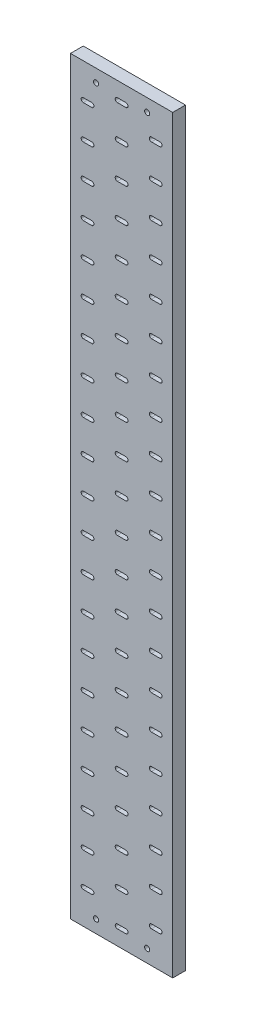
from build123d import *

# Parameters (mm, degrees)
SKETCH_1_W      = 120
SKETCH_1_H      = 880
SKETCH_1_R      = 3
EXTRUDE_1_DEPTH = 15


with BuildPart() as part:
    # 草图1 → 凸台-拉伸1 (new body)
    with BuildSketch(Plane.XY):
        with Locations((499.301234579, 90.244075086)):
            Rectangle(SKETCH_1_W, SKETCH_1_H)
        with Locations((529.301234579, 515.244075086)):
            Circle(SKETCH_1_R, mode=Mode.SUBTRACT)
        with Locations((529.301234579, -334.755924914)):
            Circle(SKETCH_1_R, mode=Mode.SUBTRACT)
        with Locations((469.301234579, 515.244075086)):
            Circle(SKETCH_1_R, mode=Mode.SUBTRACT)
        with Locations((469.301234579, -334.755924914)):
            Circle(SKETCH_1_R, mode=Mode.SUBTRACT)
        with BuildLine():
            Line((544.301234579, 492.744075086), (534.301234579, 492.744075086))
            ThreePointArc((534.301234579, 492.744075086), (531.801234579, 490.244075086), (534.301234579, 487.744075086))
            Line((534.301234579, 487.744075086), (544.301234579, 487.744075086))
            ThreePointArc((544.301234579, 487.744075086), (546.801234579, 490.244075086), (544.301234579, 492.744075086))
        make_face(mode=Mode.SUBTRACT)
        with BuildLine():
            Line((464.301234579, 492.744075086), (454.301234579, 492.744075086))
            ThreePointArc((454.301234579, 492.744075086), (451.801234579, 490.244075086), (454.301234579, 487.744075086))
            Line((454.301234579, 487.744075086), (464.301234579, 487.744075086))
            ThreePointArc((464.301234579, 487.744075086), (466.801234579, 490.244075086), (464.301234579, 492.744075086))
        make_face(mode=Mode.SUBTRACT)
        with BuildLine():
            Line((504.301234579, 472.744075086), (494.301234579, 472.744075086))
            ThreePointArc((494.301234579, 472.744075086), (491.801234579, 470.244075086), (494.301234579, 467.744075086))
            Line((494.301234579, 467.744075086), (504.301234579, 467.744075086))
            ThreePointArc((504.301234579, 467.744075086), (506.801234579, 470.244075086), (504.301234579, 472.744075086))
        make_face(mode=Mode.SUBTRACT)
        with BuildLine():
            Line((504.301234579, 512.744075086), (494.301234579, 512.744075086))
            ThreePointArc((494.301234579, 512.744075086), (491.801234579, 510.244075086), (494.301234579, 507.744075086))
            Line((494.301234579, 507.744075086), (504.301234579, 507.744075086))
            ThreePointArc((504.301234579, 507.744075086), (506.801234579, 510.244075086), (504.301234579, 512.744075086))
        make_face(mode=Mode.SUBTRACT)
        with BuildLine():
            Line((544.301234579, 452.744075086), (534.301234579, 452.744075086))
            ThreePointArc((534.301234579, 452.744075086), (531.801234579, 450.244075086), (534.301234579, 447.744075086))
            Line((534.301234579, 447.744075086), (544.301234579, 447.744075086))
            ThreePointArc((544.301234579, 447.744075086), (546.801234579, 450.244075086), (544.301234579, 452.744075086))
        make_face(mode=Mode.SUBTRACT)
        with BuildLine():
            Line((464.301234579, 452.744075086), (454.301234579, 452.744075086))
            ThreePointArc((454.301234579, 452.744075086), (451.801234579, 450.244075086), (454.301234579, 447.744075086))
            Line((454.301234579, 447.744075086), (464.301234579, 447.744075086))
            ThreePointArc((464.301234579, 447.744075086), (466.801234579, 450.244075086), (464.301234579, 452.744075086))
        make_face(mode=Mode.SUBTRACT)
        with BuildLine():
            Line((504.301234579, 432.744075086), (494.301234579, 432.744075086))
            ThreePointArc((494.301234579, 432.744075086), (491.801234579, 430.244075086), (494.301234579, 427.744075086))
            Line((494.301234579, 427.744075086), (504.301234579, 427.744075086))
            ThreePointArc((504.301234579, 427.744075086), (506.801234579, 430.244075086), (504.301234579, 432.744075086))
        make_face(mode=Mode.SUBTRACT)
        with BuildLine():
            Line((544.301234579, 412.744075086), (534.301234579, 412.744075086))
            ThreePointArc((534.301234579, 412.744075086), (531.801234579, 410.244075086), (534.301234579, 407.744075086))
            Line((534.301234579, 407.744075086), (544.301234579, 407.744075086))
            ThreePointArc((544.301234579, 407.744075086), (546.801234579, 410.244075086), (544.301234579, 412.744075086))
        make_face(mode=Mode.SUBTRACT)
        with BuildLine():
            Line((464.301234579, 412.744075086), (454.301234579, 412.744075086))
            ThreePointArc((454.301234579, 412.744075086), (451.801234579, 410.244075086), (454.301234579, 407.744075086))
            Line((454.301234579, 407.744075086), (464.301234579, 407.744075086))
            ThreePointArc((464.301234579, 407.744075086), (466.801234579, 410.244075086), (464.301234579, 412.744075086))
        make_face(mode=Mode.SUBTRACT)
        with BuildLine():
            Line((504.301234579, 392.744075086), (494.301234579, 392.744075086))
            ThreePointArc((494.301234579, 392.744075086), (491.801234579, 390.244075086), (494.301234579, 387.744075086))
            Line((494.301234579, 387.744075086), (504.301234579, 387.744075086))
            ThreePointArc((504.301234579, 387.744075086), (506.801234579, 390.244075086), (504.301234579, 392.744075086))
        make_face(mode=Mode.SUBTRACT)
        with BuildLine():
            Line((544.301234579, 372.744075086), (534.301234579, 372.744075086))
            ThreePointArc((534.301234579, 372.744075086), (531.801234579, 370.244075086), (534.301234579, 367.744075086))
            Line((534.301234579, 367.744075086), (544.301234579, 367.744075086))
            ThreePointArc((544.301234579, 367.744075086), (546.801234579, 370.244075086), (544.301234579, 372.744075086))
        make_face(mode=Mode.SUBTRACT)
        with BuildLine():
            Line((464.301234579, 372.744075086), (454.301234579, 372.744075086))
            ThreePointArc((454.301234579, 372.744075086), (451.801234579, 370.244075086), (454.301234579, 367.744075086))
            Line((454.301234579, 367.744075086), (464.301234579, 367.744075086))
            ThreePointArc((464.301234579, 367.744075086), (466.801234579, 370.244075086), (464.301234579, 372.744075086))
        make_face(mode=Mode.SUBTRACT)
        with BuildLine():
            Line((504.301234579, 352.744075086), (494.301234579, 352.744075086))
            ThreePointArc((494.301234579, 352.744075086), (491.801234579, 350.244075086), (494.301234579, 347.744075086))
            Line((494.301234579, 347.744075086), (504.301234579, 347.744075086))
            ThreePointArc((504.301234579, 347.744075086), (506.801234579, 350.244075086), (504.301234579, 352.744075086))
        make_face(mode=Mode.SUBTRACT)
        with BuildLine():
            Line((544.301234579, 332.744075086), (534.301234579, 332.744075086))
            ThreePointArc((534.301234579, 332.744075086), (531.801234579, 330.244075086), (534.301234579, 327.744075086))
            Line((534.301234579, 327.744075086), (544.301234579, 327.744075086))
            ThreePointArc((544.301234579, 327.744075086), (546.801234579, 330.244075086), (544.301234579, 332.744075086))
        make_face(mode=Mode.SUBTRACT)
        with BuildLine():
            Line((464.301234579, 332.744075086), (454.301234579, 332.744075086))
            ThreePointArc((454.301234579, 332.744075086), (451.801234579, 330.244075086), (454.301234579, 327.744075086))
            Line((454.301234579, 327.744075086), (464.301234579, 327.744075086))
            ThreePointArc((464.301234579, 327.744075086), (466.801234579, 330.244075086), (464.301234579, 332.744075086))
        make_face(mode=Mode.SUBTRACT)
        with BuildLine():
            Line((504.301234579, 312.744075086), (494.301234579, 312.744075086))
            ThreePointArc((494.301234579, 312.744075086), (491.801234579, 310.244075086), (494.301234579, 307.744075086))
            Line((494.301234579, 307.744075086), (504.301234579, 307.744075086))
            ThreePointArc((504.301234579, 307.744075086), (506.801234579, 310.244075086), (504.301234579, 312.744075086))
        make_face(mode=Mode.SUBTRACT)
        with BuildLine():
            Line((544.301234579, 292.744075086), (534.301234579, 292.744075086))
            ThreePointArc((534.301234579, 292.744075086), (531.801234579, 290.244075086), (534.301234579, 287.744075086))
            Line((534.301234579, 287.744075086), (544.301234579, 287.744075086))
            ThreePointArc((544.301234579, 287.744075086), (546.801234579, 290.244075086), (544.301234579, 292.744075086))
        make_face(mode=Mode.SUBTRACT)
        with BuildLine():
            Line((464.301234579, 292.744075086), (454.301234579, 292.744075086))
            ThreePointArc((454.301234579, 292.744075086), (451.801234579, 290.244075086), (454.301234579, 287.744075086))
            Line((454.301234579, 287.744075086), (464.301234579, 287.744075086))
            ThreePointArc((464.301234579, 287.744075086), (466.801234579, 290.244075086), (464.301234579, 292.744075086))
        make_face(mode=Mode.SUBTRACT)
        with BuildLine():
            Line((504.301234579, 272.744075086), (494.301234579, 272.744075086))
            ThreePointArc((494.301234579, 272.744075086), (491.801234579, 270.244075086), (494.301234579, 267.744075086))
            Line((494.301234579, 267.744075086), (504.301234579, 267.744075086))
            ThreePointArc((504.301234579, 267.744075086), (506.801234579, 270.244075086), (504.301234579, 272.744075086))
        make_face(mode=Mode.SUBTRACT)
        with BuildLine():
            Line((544.301234579, 252.744075086), (534.301234579, 252.744075086))
            ThreePointArc((534.301234579, 252.744075086), (531.801234579, 250.244075086), (534.301234579, 247.744075086))
            Line((534.301234579, 247.744075086), (544.301234579, 247.744075086))
            ThreePointArc((544.301234579, 247.744075086), (546.801234579, 250.244075086), (544.301234579, 252.744075086))
        make_face(mode=Mode.SUBTRACT)
        with BuildLine():
            Line((464.301234579, 252.744075086), (454.301234579, 252.744075086))
            ThreePointArc((454.301234579, 252.744075086), (451.801234579, 250.244075086), (454.301234579, 247.744075086))
            Line((454.301234579, 247.744075086), (464.301234579, 247.744075086))
            ThreePointArc((464.301234579, 247.744075086), (466.801234579, 250.244075086), (464.301234579, 252.744075086))
        make_face(mode=Mode.SUBTRACT)
        with BuildLine():
            Line((504.301234579, 232.744075086), (494.301234579, 232.744075086))
            ThreePointArc((494.301234579, 232.744075086), (491.801234579, 230.244075086), (494.301234579, 227.744075086))
            Line((494.301234579, 227.744075086), (504.301234579, 227.744075086))
            ThreePointArc((504.301234579, 227.744075086), (506.801234579, 230.244075086), (504.301234579, 232.744075086))
        make_face(mode=Mode.SUBTRACT)
        with BuildLine():
            Line((544.301234579, 212.744075086), (534.301234579, 212.744075086))
            ThreePointArc((534.301234579, 212.744075086), (531.801234579, 210.244075086), (534.301234579, 207.744075086))
            Line((534.301234579, 207.744075086), (544.301234579, 207.744075086))
            ThreePointArc((544.301234579, 207.744075086), (546.801234579, 210.244075086), (544.301234579, 212.744075086))
        make_face(mode=Mode.SUBTRACT)
        with BuildLine():
            Line((464.301234579, 212.744075086), (454.301234579, 212.744075086))
            ThreePointArc((454.301234579, 212.744075086), (451.801234579, 210.244075086), (454.301234579, 207.744075086))
            Line((454.301234579, 207.744075086), (464.301234579, 207.744075086))
            ThreePointArc((464.301234579, 207.744075086), (466.801234579, 210.244075086), (464.301234579, 212.744075086))
        make_face(mode=Mode.SUBTRACT)
        with BuildLine():
            Line((504.301234579, 192.744075086), (494.301234579, 192.744075086))
            ThreePointArc((494.301234579, 192.744075086), (491.801234579, 190.244075086), (494.301234579, 187.744075086))
            Line((494.301234579, 187.744075086), (504.301234579, 187.744075086))
            ThreePointArc((504.301234579, 187.744075086), (506.801234579, 190.244075086), (504.301234579, 192.744075086))
        make_face(mode=Mode.SUBTRACT)
        with BuildLine():
            Line((544.301234579, 172.744075086), (534.301234579, 172.744075086))
            ThreePointArc((534.301234579, 172.744075086), (531.801234579, 170.244075086), (534.301234579, 167.744075086))
            Line((534.301234579, 167.744075086), (544.301234579, 167.744075086))
            ThreePointArc((544.301234579, 167.744075086), (546.801234579, 170.244075086), (544.301234579, 172.744075086))
        make_face(mode=Mode.SUBTRACT)
        with BuildLine():
            Line((464.301234579, 172.744075086), (454.301234579, 172.744075086))
            ThreePointArc((454.301234579, 172.744075086), (451.801234579, 170.244075086), (454.301234579, 167.744075086))
            Line((454.301234579, 167.744075086), (464.301234579, 167.744075086))
            ThreePointArc((464.301234579, 167.744075086), (466.801234579, 170.244075086), (464.301234579, 172.744075086))
        make_face(mode=Mode.SUBTRACT)
        with BuildLine():
            Line((504.301234579, 152.744075086), (494.301234579, 152.744075086))
            ThreePointArc((494.301234579, 152.744075086), (491.801234579, 150.244075086), (494.301234579, 147.744075086))
            Line((494.301234579, 147.744075086), (504.301234579, 147.744075086))
            ThreePointArc((504.301234579, 147.744075086), (506.801234579, 150.244075086), (504.301234579, 152.744075086))
        make_face(mode=Mode.SUBTRACT)
        with BuildLine():
            Line((544.301234579, 132.744075086), (534.301234579, 132.744075086))
            ThreePointArc((534.301234579, 132.744075086), (531.801234579, 130.244075086), (534.301234579, 127.744075086))
            Line((534.301234579, 127.744075086), (544.301234579, 127.744075086))
            ThreePointArc((544.301234579, 127.744075086), (546.801234579, 130.244075086), (544.301234579, 132.744075086))
        make_face(mode=Mode.SUBTRACT)
        with BuildLine():
            Line((464.301234579, 132.744075086), (454.301234579, 132.744075086))
            ThreePointArc((454.301234579, 132.744075086), (451.801234579, 130.244075086), (454.301234579, 127.744075086))
            Line((454.301234579, 127.744075086), (464.301234579, 127.744075086))
            ThreePointArc((464.301234579, 127.744075086), (466.801234579, 130.244075086), (464.301234579, 132.744075086))
        make_face(mode=Mode.SUBTRACT)
        with BuildLine():
            Line((504.301234579, 112.744075086), (494.301234579, 112.744075086))
            ThreePointArc((494.301234579, 112.744075086), (491.801234579, 110.244075086), (494.301234579, 107.744075086))
            Line((494.301234579, 107.744075086), (504.301234579, 107.744075086))
            ThreePointArc((504.301234579, 107.744075086), (506.801234579, 110.244075086), (504.301234579, 112.744075086))
        make_face(mode=Mode.SUBTRACT)
        with BuildLine():
            Line((544.301234579, 92.744075086), (534.301234579, 92.744075086))
            ThreePointArc((534.301234579, 92.744075086), (531.801234579, 90.244075086), (534.301234579, 87.744075086))
            Line((534.301234579, 87.744075086), (544.301234579, 87.744075086))
            ThreePointArc((544.301234579, 87.744075086), (546.801234579, 90.244075086), (544.301234579, 92.744075086))
        make_face(mode=Mode.SUBTRACT)
        with BuildLine():
            Line((464.301234579, 92.744075086), (454.301234579, 92.744075086))
            ThreePointArc((454.301234579, 92.744075086), (451.801234579, 90.244075086), (454.301234579, 87.744075086))
            Line((454.301234579, 87.744075086), (464.301234579, 87.744075086))
            ThreePointArc((464.301234579, 87.744075086), (466.801234579, 90.244075086), (464.301234579, 92.744075086))
        make_face(mode=Mode.SUBTRACT)
        with BuildLine():
            Line((504.301234579, 72.744075086), (494.301234579, 72.744075086))
            ThreePointArc((494.301234579, 72.744075086), (491.801234579, 70.244075086), (494.301234579, 67.744075086))
            Line((494.301234579, 67.744075086), (504.301234579, 67.744075086))
            ThreePointArc((504.301234579, 67.744075086), (506.801234579, 70.244075086), (504.301234579, 72.744075086))
        make_face(mode=Mode.SUBTRACT)
        with BuildLine():
            Line((544.301234579, 52.744075086), (534.301234579, 52.744075086))
            ThreePointArc((534.301234579, 52.744075086), (531.801234579, 50.244075086), (534.301234579, 47.744075086))
            Line((534.301234579, 47.744075086), (544.301234579, 47.744075086))
            ThreePointArc((544.301234579, 47.744075086), (546.801234579, 50.244075086), (544.301234579, 52.744075086))
        make_face(mode=Mode.SUBTRACT)
        with BuildLine():
            Line((464.301234579, 52.744075086), (454.301234579, 52.744075086))
            ThreePointArc((454.301234579, 52.744075086), (451.801234579, 50.244075086), (454.301234579, 47.744075086))
            Line((454.301234579, 47.744075086), (464.301234579, 47.744075086))
            ThreePointArc((464.301234579, 47.744075086), (466.801234579, 50.244075086), (464.301234579, 52.744075086))
        make_face(mode=Mode.SUBTRACT)
        with BuildLine():
            Line((504.301234579, 32.744075086), (494.301234579, 32.744075086))
            ThreePointArc((494.301234579, 32.744075086), (491.801234579, 30.244075086), (494.301234579, 27.744075086))
            Line((494.301234579, 27.744075086), (504.301234579, 27.744075086))
            ThreePointArc((504.301234579, 27.744075086), (506.801234579, 30.244075086), (504.301234579, 32.744075086))
        make_face(mode=Mode.SUBTRACT)
        with BuildLine():
            Line((544.301234579, 12.744075086), (534.301234579, 12.744075086))
            ThreePointArc((534.301234579, 12.744075086), (531.801234579, 10.244075086), (534.301234579, 7.744075086))
            Line((534.301234579, 7.744075086), (544.301234579, 7.744075086))
            ThreePointArc((544.301234579, 7.744075086), (546.801234579, 10.244075086), (544.301234579, 12.744075086))
        make_face(mode=Mode.SUBTRACT)
        with BuildLine():
            Line((464.301234579, 12.744075086), (454.301234579, 12.744075086))
            ThreePointArc((454.301234579, 12.744075086), (451.801234579, 10.244075086), (454.301234579, 7.744075086))
            Line((454.301234579, 7.744075086), (464.301234579, 7.744075086))
            ThreePointArc((464.301234579, 7.744075086), (466.801234579, 10.244075086), (464.301234579, 12.744075086))
        make_face(mode=Mode.SUBTRACT)
        with BuildLine():
            Line((504.301234579, -7.255924914), (494.301234579, -7.255924914))
            ThreePointArc((494.301234579, -7.255924914), (491.801234579, -9.755924914), (494.301234579, -12.255924914))
            Line((494.301234579, -12.255924914), (504.301234579, -12.255924914))
            ThreePointArc((504.301234579, -12.255924914), (506.801234579, -9.755924914), (504.301234579, -7.255924914))
        make_face(mode=Mode.SUBTRACT)
        with BuildLine():
            Line((544.301234579, -27.255924914), (534.301234579, -27.255924914))
            ThreePointArc((534.301234579, -27.255924914), (531.801234579, -29.755924914), (534.301234579, -32.255924914))
            Line((534.301234579, -32.255924914), (544.301234579, -32.255924914))
            ThreePointArc((544.301234579, -32.255924914), (546.801234579, -29.755924914), (544.301234579, -27.255924914))
        make_face(mode=Mode.SUBTRACT)
        with BuildLine():
            Line((464.301234579, -27.255924914), (454.301234579, -27.255924914))
            ThreePointArc((454.301234579, -27.255924914), (451.801234579, -29.755924914), (454.301234579, -32.255924914))
            Line((454.301234579, -32.255924914), (464.301234579, -32.255924914))
            ThreePointArc((464.301234579, -32.255924914), (466.801234579, -29.755924914), (464.301234579, -27.255924914))
        make_face(mode=Mode.SUBTRACT)
        with BuildLine():
            Line((504.301234579, -47.255924914), (494.301234579, -47.255924914))
            ThreePointArc((494.301234579, -47.255924914), (491.801234579, -49.755924914), (494.301234579, -52.255924914))
            Line((494.301234579, -52.255924914), (504.301234579, -52.255924914))
            ThreePointArc((504.301234579, -52.255924914), (506.801234579, -49.755924914), (504.301234579, -47.255924914))
        make_face(mode=Mode.SUBTRACT)
        with BuildLine():
            Line((544.301234579, -67.255924914), (534.301234579, -67.255924914))
            ThreePointArc((534.301234579, -67.255924914), (531.801234579, -69.755924914), (534.301234579, -72.255924914))
            Line((534.301234579, -72.255924914), (544.301234579, -72.255924914))
            ThreePointArc((544.301234579, -72.255924914), (546.801234579, -69.755924914), (544.301234579, -67.255924914))
        make_face(mode=Mode.SUBTRACT)
        with BuildLine():
            Line((464.301234579, -67.255924914), (454.301234579, -67.255924914))
            ThreePointArc((454.301234579, -67.255924914), (451.801234579, -69.755924914), (454.301234579, -72.255924914))
            Line((454.301234579, -72.255924914), (464.301234579, -72.255924914))
            ThreePointArc((464.301234579, -72.255924914), (466.801234579, -69.755924914), (464.301234579, -67.255924914))
        make_face(mode=Mode.SUBTRACT)
        with BuildLine():
            Line((504.301234579, -87.255924914), (494.301234579, -87.255924914))
            ThreePointArc((494.301234579, -87.255924914), (491.801234579, -89.755924914), (494.301234579, -92.255924914))
            Line((494.301234579, -92.255924914), (504.301234579, -92.255924914))
            ThreePointArc((504.301234579, -92.255924914), (506.801234579, -89.755924914), (504.301234579, -87.255924914))
        make_face(mode=Mode.SUBTRACT)
        with BuildLine():
            Line((544.301234579, -107.255924914), (534.301234579, -107.255924914))
            ThreePointArc((534.301234579, -107.255924914), (531.801234579, -109.755924914), (534.301234579, -112.255924914))
            Line((534.301234579, -112.255924914), (544.301234579, -112.255924914))
            ThreePointArc((544.301234579, -112.255924914), (546.801234579, -109.755924914), (544.301234579, -107.255924914))
        make_face(mode=Mode.SUBTRACT)
        with BuildLine():
            Line((464.301234579, -107.255924914), (454.301234579, -107.255924914))
            ThreePointArc((454.301234579, -107.255924914), (451.801234579, -109.755924914), (454.301234579, -112.255924914))
            Line((454.301234579, -112.255924914), (464.301234579, -112.255924914))
            ThreePointArc((464.301234579, -112.255924914), (466.801234579, -109.755924914), (464.301234579, -107.255924914))
        make_face(mode=Mode.SUBTRACT)
        with BuildLine():
            Line((504.301234579, -127.255924914), (494.301234579, -127.255924914))
            ThreePointArc((494.301234579, -127.255924914), (491.801234579, -129.755924914), (494.301234579, -132.255924914))
            Line((494.301234579, -132.255924914), (504.301234579, -132.255924914))
            ThreePointArc((504.301234579, -132.255924914), (506.801234579, -129.755924914), (504.301234579, -127.255924914))
        make_face(mode=Mode.SUBTRACT)
        with BuildLine():
            Line((544.301234579, -147.255924914), (534.301234579, -147.255924914))
            ThreePointArc((534.301234579, -147.255924914), (531.801234579, -149.755924914), (534.301234579, -152.255924914))
            Line((534.301234579, -152.255924914), (544.301234579, -152.255924914))
            ThreePointArc((544.301234579, -152.255924914), (546.801234579, -149.755924914), (544.301234579, -147.255924914))
        make_face(mode=Mode.SUBTRACT)
        with BuildLine():
            Line((464.301234579, -147.255924914), (454.301234579, -147.255924914))
            ThreePointArc((454.301234579, -147.255924914), (451.801234579, -149.755924914), (454.301234579, -152.255924914))
            Line((454.301234579, -152.255924914), (464.301234579, -152.255924914))
            ThreePointArc((464.301234579, -152.255924914), (466.801234579, -149.755924914), (464.301234579, -147.255924914))
        make_face(mode=Mode.SUBTRACT)
        with BuildLine():
            Line((504.301234579, -167.255924914), (494.301234579, -167.255924914))
            ThreePointArc((494.301234579, -167.255924914), (491.801234579, -169.755924914), (494.301234579, -172.255924914))
            Line((494.301234579, -172.255924914), (504.301234579, -172.255924914))
            ThreePointArc((504.301234579, -172.255924914), (506.801234579, -169.755924914), (504.301234579, -167.255924914))
        make_face(mode=Mode.SUBTRACT)
        with BuildLine():
            Line((544.301234579, -187.255924914), (534.301234579, -187.255924914))
            ThreePointArc((534.301234579, -187.255924914), (531.801234579, -189.755924914), (534.301234579, -192.255924914))
            Line((534.301234579, -192.255924914), (544.301234579, -192.255924914))
            ThreePointArc((544.301234579, -192.255924914), (546.801234579, -189.755924914), (544.301234579, -187.255924914))
        make_face(mode=Mode.SUBTRACT)
        with BuildLine():
            Line((464.301234579, -187.255924914), (454.301234579, -187.255924914))
            ThreePointArc((454.301234579, -187.255924914), (451.801234579, -189.755924914), (454.301234579, -192.255924914))
            Line((454.301234579, -192.255924914), (464.301234579, -192.255924914))
            ThreePointArc((464.301234579, -192.255924914), (466.801234579, -189.755924914), (464.301234579, -187.255924914))
        make_face(mode=Mode.SUBTRACT)
        with BuildLine():
            Line((504.301234579, -207.255924914), (494.301234579, -207.255924914))
            ThreePointArc((494.301234579, -207.255924914), (491.801234579, -209.755924914), (494.301234579, -212.255924914))
            Line((494.301234579, -212.255924914), (504.301234579, -212.255924914))
            ThreePointArc((504.301234579, -212.255924914), (506.801234579, -209.755924914), (504.301234579, -207.255924914))
        make_face(mode=Mode.SUBTRACT)
        with BuildLine():
            Line((544.301234579, -227.255924914), (534.301234579, -227.255924914))
            ThreePointArc((534.301234579, -227.255924914), (531.801234579, -229.755924914), (534.301234579, -232.255924914))
            Line((534.301234579, -232.255924914), (544.301234579, -232.255924914))
            ThreePointArc((544.301234579, -232.255924914), (546.801234579, -229.755924914), (544.301234579, -227.255924914))
        make_face(mode=Mode.SUBTRACT)
        with BuildLine():
            Line((464.301234579, -227.255924914), (454.301234579, -227.255924914))
            ThreePointArc((454.301234579, -227.255924914), (451.801234579, -229.755924914), (454.301234579, -232.255924914))
            Line((454.301234579, -232.255924914), (464.301234579, -232.255924914))
            ThreePointArc((464.301234579, -232.255924914), (466.801234579, -229.755924914), (464.301234579, -227.255924914))
        make_face(mode=Mode.SUBTRACT)
        with BuildLine():
            Line((504.301234579, -247.255924914), (494.301234579, -247.255924914))
            ThreePointArc((494.301234579, -247.255924914), (491.801234579, -249.755924914), (494.301234579, -252.255924914))
            Line((494.301234579, -252.255924914), (504.301234579, -252.255924914))
            ThreePointArc((504.301234579, -252.255924914), (506.801234579, -249.755924914), (504.301234579, -247.255924914))
        make_face(mode=Mode.SUBTRACT)
        with BuildLine():
            Line((544.301234579, -267.255924914), (534.301234579, -267.255924914))
            ThreePointArc((534.301234579, -267.255924914), (531.801234579, -269.755924914), (534.301234579, -272.255924914))
            Line((534.301234579, -272.255924914), (544.301234579, -272.255924914))
            ThreePointArc((544.301234579, -272.255924914), (546.801234579, -269.755924914), (544.301234579, -267.255924914))
        make_face(mode=Mode.SUBTRACT)
        with BuildLine():
            Line((464.301234579, -267.255924914), (454.301234579, -267.255924914))
            ThreePointArc((454.301234579, -267.255924914), (451.801234579, -269.755924914), (454.301234579, -272.255924914))
            Line((454.301234579, -272.255924914), (464.301234579, -272.255924914))
            ThreePointArc((464.301234579, -272.255924914), (466.801234579, -269.755924914), (464.301234579, -267.255924914))
        make_face(mode=Mode.SUBTRACT)
        with BuildLine():
            Line((504.301234579, -287.255924914), (494.301234579, -287.255924914))
            ThreePointArc((494.301234579, -287.255924914), (491.801234579, -289.755924914), (494.301234579, -292.255924914))
            Line((494.301234579, -292.255924914), (504.301234579, -292.255924914))
            ThreePointArc((504.301234579, -292.255924914), (506.801234579, -289.755924914), (504.301234579, -287.255924914))
        make_face(mode=Mode.SUBTRACT)
        with BuildLine():
            Line((544.301234579, -307.255924914), (534.301234579, -307.255924914))
            ThreePointArc((534.301234579, -307.255924914), (531.801234579, -309.755924914), (534.301234579, -312.255924914))
            Line((534.301234579, -312.255924914), (544.301234579, -312.255924914))
            ThreePointArc((544.301234579, -312.255924914), (546.801234579, -309.755924914), (544.301234579, -307.255924914))
        make_face(mode=Mode.SUBTRACT)
        with BuildLine():
            Line((464.301234579, -307.255924914), (454.301234579, -307.255924914))
            ThreePointArc((454.301234579, -307.255924914), (451.801234579, -309.755924914), (454.301234579, -312.255924914))
            Line((454.301234579, -312.255924914), (464.301234579, -312.255924914))
            ThreePointArc((464.301234579, -312.255924914), (466.801234579, -309.755924914), (464.301234579, -307.255924914))
        make_face(mode=Mode.SUBTRACT)
        with BuildLine():
            Line((504.301234579, -327.255924914), (494.301234579, -327.255924914))
            ThreePointArc((494.301234579, -327.255924914), (491.801234579, -329.755924914), (494.301234579, -332.255924914))
            Line((494.301234579, -332.255924914), (504.301234579, -332.255924914))
            ThreePointArc((504.301234579, -332.255924914), (506.801234579, -329.755924914), (504.301234579, -327.255924914))
        make_face(mode=Mode.SUBTRACT)
    extrude(amount=EXTRUDE_1_DEPTH)


solid = part.part
